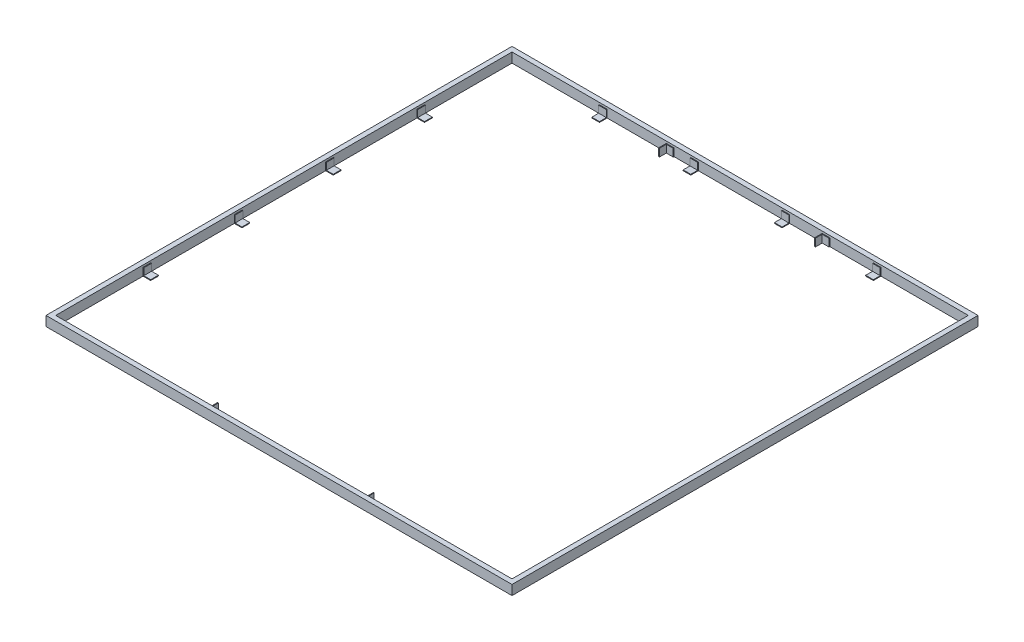
from build123d import *

# Parameters (mm, degrees)
SKETCH1_W                = 3660
SKETCH1_H                = 3660
SKETCH1_W_2              = 3584
SKETCH1_H_2              = 3584
BOSS_EXTRUDE1_DEPTH      = 76
SKETCH2_W                = 60
SKETCH2_H                = 60
BOSS_EXTRUDE2_DEPTH      = 6
SKETCH4_W                = 60
SKETCH4_H                = 6
BOSS_EXTRUDE3_DEPTH      = 54
LPATTERN1_COUNT          = 4
LPATTERN1_PITCH          = 717
MIRROR1_COPY_1_SKETCH_W  = 60
MIRROR1_COPY_1_SKETCH_H  = 60
MIRROR1_COPY_1_DEPTH     = 6
MIRROR1_COPY_2_SKETCH_W  = 60
MIRROR1_COPY_2_SKETCH_H  = 60
MIRROR1_COPY_2_DEPTH     = 6
MIRROR1_COPY_3_SKETCH_W  = 60
MIRROR1_COPY_3_SKETCH_H  = 60
MIRROR1_COPY_3_DEPTH     = 6
MIRROR1_COPY_4_SKETCH_W  = 60
MIRROR1_COPY_4_SKETCH_H  = 6
MIRROR1_COPY_4_DEPTH     = 54
MIRROR1_COPY_5_SKETCH_W  = 60
MIRROR1_COPY_5_SKETCH_H  = 6
MIRROR1_COPY_5_DEPTH     = 54
MIRROR1_COPY_6_SKETCH_W  = 60
MIRROR1_COPY_6_SKETCH_H  = 6
MIRROR1_COPY_6_DEPTH     = 54
MIRROR2_COPY_1_SKETCH_W  = 60
MIRROR2_COPY_1_SKETCH_H  = 60
MIRROR2_COPY_1_DEPTH     = 6
MIRROR2_COPY_2_SKETCH_W  = 60
MIRROR2_COPY_2_SKETCH_H  = 60
MIRROR2_COPY_2_DEPTH     = 6
MIRROR2_COPY_3_SKETCH_W  = 60
MIRROR2_COPY_3_SKETCH_H  = 60
MIRROR2_COPY_3_DEPTH     = 6
MIRROR2_COPY_4_SKETCH_W  = 60
MIRROR2_COPY_4_SKETCH_H  = 6
MIRROR2_COPY_4_DEPTH     = 54
MIRROR2_COPY_5_SKETCH_W  = 60
MIRROR2_COPY_5_SKETCH_H  = 6
MIRROR2_COPY_5_DEPTH     = 54
MIRROR2_COPY_6_SKETCH_W  = 60
MIRROR2_COPY_6_SKETCH_H  = 6
MIRROR2_COPY_6_DEPTH     = 54
MIRROR3_COPY_1_SKETCH_W  = 60
MIRROR3_COPY_1_SKETCH_H  = 60
MIRROR3_COPY_1_DEPTH     = 6
MIRROR3_COPY_2_SKETCH_W  = 60
MIRROR3_COPY_2_SKETCH_H  = 6
MIRROR3_COPY_2_DEPTH     = 54
MIRROR3_COPY_3_SKETCH_W  = 60
MIRROR3_COPY_3_SKETCH_H  = 60
MIRROR3_COPY_3_DEPTH     = 6
MIRROR3_COPY_4_SKETCH_W  = 60
MIRROR3_COPY_4_SKETCH_H  = 60
MIRROR3_COPY_4_DEPTH     = 6
MIRROR3_COPY_5_SKETCH_W  = 60
MIRROR3_COPY_5_SKETCH_H  = 60
MIRROR3_COPY_5_DEPTH     = 6
MIRROR3_COPY_6_SKETCH_W  = 60
MIRROR3_COPY_6_SKETCH_H  = 6
MIRROR3_COPY_6_DEPTH     = 54
MIRROR3_COPY_7_SKETCH_W  = 60
MIRROR3_COPY_7_SKETCH_H  = 6
MIRROR3_COPY_7_DEPTH     = 54
MIRROR3_COPY_8_SKETCH_W  = 60
MIRROR3_COPY_8_SKETCH_H  = 6
MIRROR3_COPY_8_DEPTH     = 54
MIRROR3_COPY_9_SKETCH_W  = 60
MIRROR3_COPY_9_SKETCH_H  = 6
MIRROR3_COPY_9_DEPTH     = 54
MIRROR3_COPY_10_SKETCH_W = 60
MIRROR3_COPY_10_SKETCH_H = 60
MIRROR3_COPY_10_DEPTH    = 6
MIRROR3_COPY_11_SKETCH_W = 60
MIRROR3_COPY_11_SKETCH_H = 60
MIRROR3_COPY_11_DEPTH    = 6
MIRROR3_COPY_12_SKETCH_W = 60
MIRROR3_COPY_12_SKETCH_H = 60
MIRROR3_COPY_12_DEPTH    = 6
MIRROR3_COPY_13_SKETCH_W = 60
MIRROR3_COPY_13_SKETCH_H = 6
MIRROR3_COPY_13_DEPTH    = 54
MIRROR3_COPY_14_SKETCH_W = 60
MIRROR3_COPY_14_SKETCH_H = 6
MIRROR3_COPY_14_DEPTH    = 54
MIRROR3_COPY_15_SKETCH_W = 60
MIRROR3_COPY_15_SKETCH_H = 6
MIRROR3_COPY_15_DEPTH    = 54
MIRROR3_COPY_16_SKETCH_W = 60
MIRROR3_COPY_16_SKETCH_H = 6
MIRROR3_COPY_16_DEPTH    = 54
SKETCH5_W                = 60
SKETCH5_H                = 60
BOSS_EXTRUDE4_DEPTH      = 60
SKETCH7_W                = 54
SKETCH7_H                = 54
CUT_EXTRUDE2_DEPTH       = 60
LPATTERN2_COUNT          = 2
LPATTERN2_PITCH          = 1224
MIRROR4_COPY_1_SKETCH_W  = 60
MIRROR4_COPY_1_SKETCH_H  = 60
MIRROR4_COPY_1_DEPTH     = 60
MIRROR4_COPY_2_SKETCH_W  = 54
MIRROR4_COPY_2_SKETCH_H  = 54
MIRROR4_COPY_2_DEPTH     = 60


with BuildPart() as part:
    # Sketch1 → Boss-Extrude1 (new body)
    with BuildSketch(Plane(origin=(0, 0, 0), x_dir=(1, 0, 0), z_dir=(0, 1, 0))):
        Rectangle(SKETCH1_W, SKETCH1_H)
        Rectangle(SKETCH1_W_2, SKETCH1_H_2, mode=Mode.SUBTRACT)
    extrude(amount=BOSS_EXTRUDE1_DEPTH)

    # Sketch2 → Boss-Extrude2 (add)
    with BuildSketch(Plane(origin=(-1792, 0, 0), x_dir=(0, 0, -1), z_dir=(1, 0, 0))):
        with Locations((-1075, 30)):
            Rectangle(SKETCH2_W, SKETCH2_H)
    boss_extrude2 = extrude(amount=BOSS_EXTRUDE2_DEPTH)

    # Sketch4 → Boss-Extrude3 (add)
    with BuildSketch(Plane(origin=(-1786, 0, 0), x_dir=(0, 0, -1), z_dir=(1, 0, 0))):
        with Locations((-1075, 3)):
            Rectangle(SKETCH4_W, SKETCH4_H)
    boss_extrude3 = extrude(amount=BOSS_EXTRUDE3_DEPTH)

    # LPattern1: Boss-Extrude2, Boss-Extrude3 ×4
    with Locations(*[(0, 0, -i * LPATTERN1_PITCH) for i in range(1, LPATTERN1_COUNT)]):
        add(boss_extrude2)
        add(boss_extrude3)

    # Mirror1: Boss-Extrude2, Boss-Extrude3 across plane
    add(boss_extrude2.mirror(Plane(origin=(0, 0, 0), x_dir=(0, 0, 1), z_dir=(1, 0, 0))))
    add(boss_extrude3.mirror(Plane(origin=(0, 0, 0), x_dir=(0, 0, 1), z_dir=(1, 0, 0))))

    # Mirror1 copy 1 sketch → Mirror1 copy 1 (add)
    with BuildSketch(Plane(origin=(1792, 0, -717), x_dir=(0, 0, -1), z_dir=(-1, 0, 0))):
        with Locations((-1075, -30)):
            Rectangle(MIRROR1_COPY_1_SKETCH_W, MIRROR1_COPY_1_SKETCH_H)
    extrude(amount=MIRROR1_COPY_1_DEPTH)

    # Mirror1 copy 2 sketch → Mirror1 copy 2 (add)
    with BuildSketch(Plane(origin=(1792, 0, -1434), x_dir=(0, 0, -1), z_dir=(-1, 0, 0))):
        with Locations((-1075, -30)):
            Rectangle(MIRROR1_COPY_2_SKETCH_W, MIRROR1_COPY_2_SKETCH_H)
    extrude(amount=MIRROR1_COPY_2_DEPTH)

    # Mirror1 copy 3 sketch → Mirror1 copy 3 (add)
    with BuildSketch(Plane(origin=(1792, 0, -2151), x_dir=(0, 0, -1), z_dir=(-1, 0, 0))):
        with Locations((-1075, -30)):
            Rectangle(MIRROR1_COPY_3_SKETCH_W, MIRROR1_COPY_3_SKETCH_H)
    extrude(amount=MIRROR1_COPY_3_DEPTH)

    # Mirror1 copy 4 sketch → Mirror1 copy 4 (add)
    with BuildSketch(Plane(origin=(1786, 0, -717), x_dir=(0, 0, -1), z_dir=(-1, 0, 0))):
        with Locations((-1075, -3)):
            Rectangle(MIRROR1_COPY_4_SKETCH_W, MIRROR1_COPY_4_SKETCH_H)
    extrude(amount=MIRROR1_COPY_4_DEPTH)

    # Mirror1 copy 5 sketch → Mirror1 copy 5 (add)
    with BuildSketch(Plane(origin=(1786, 0, -1434), x_dir=(0, 0, -1), z_dir=(-1, 0, 0))):
        with Locations((-1075, -3)):
            Rectangle(MIRROR1_COPY_5_SKETCH_W, MIRROR1_COPY_5_SKETCH_H)
    extrude(amount=MIRROR1_COPY_5_DEPTH)

    # Mirror1 copy 6 sketch → Mirror1 copy 6 (add)
    with BuildSketch(Plane(origin=(1786, 0, -2151), x_dir=(0, 0, -1), z_dir=(-1, 0, 0))):
        with Locations((-1075, -3)):
            Rectangle(MIRROR1_COPY_6_SKETCH_W, MIRROR1_COPY_6_SKETCH_H)
    extrude(amount=MIRROR1_COPY_6_DEPTH)

    # Mirror2: Boss-Extrude2, Boss-Extrude3 across plane
    add(boss_extrude2.mirror(Plane(origin=(0, 0, 0), x_dir=(-0.707106781, 0, 0.707106781), z_dir=(-0.707106781, 0, -0.707106781))))
    add(boss_extrude3.mirror(Plane(origin=(0, 0, 0), x_dir=(-0.707106781, 0, 0.707106781), z_dir=(-0.707106781, 0, -0.707106781))))

    # Mirror2 copy 1 sketch → Mirror2 copy 1 (add)
    with BuildSketch(Plane(origin=(717, 0, 1792), x_dir=(1, 0, 0), z_dir=(0, 0, -1))):
        with Locations((-1075, -30)):
            Rectangle(MIRROR2_COPY_1_SKETCH_W, MIRROR2_COPY_1_SKETCH_H)
    extrude(amount=MIRROR2_COPY_1_DEPTH)

    # Mirror2 copy 2 sketch → Mirror2 copy 2 (add)
    with BuildSketch(Plane(origin=(1434, 0, 1792), x_dir=(1, 0, 0), z_dir=(0, 0, -1))):
        with Locations((-1075, -30)):
            Rectangle(MIRROR2_COPY_2_SKETCH_W, MIRROR2_COPY_2_SKETCH_H)
    extrude(amount=MIRROR2_COPY_2_DEPTH)

    # Mirror2 copy 3 sketch → Mirror2 copy 3 (add)
    with BuildSketch(Plane(origin=(2151, 0, 1792), x_dir=(1, 0, 0), z_dir=(0, 0, -1))):
        with Locations((-1075, -30)):
            Rectangle(MIRROR2_COPY_3_SKETCH_W, MIRROR2_COPY_3_SKETCH_H)
    extrude(amount=MIRROR2_COPY_3_DEPTH)

    # Mirror2 copy 4 sketch → Mirror2 copy 4 (add)
    with BuildSketch(Plane(origin=(717, 0, 1786), x_dir=(1, 0, 0), z_dir=(0, 0, -1))):
        with Locations((-1075, -3)):
            Rectangle(MIRROR2_COPY_4_SKETCH_W, MIRROR2_COPY_4_SKETCH_H)
    extrude(amount=MIRROR2_COPY_4_DEPTH)

    # Mirror2 copy 5 sketch → Mirror2 copy 5 (add)
    with BuildSketch(Plane(origin=(1434, 0, 1786), x_dir=(1, 0, 0), z_dir=(0, 0, -1))):
        with Locations((-1075, -3)):
            Rectangle(MIRROR2_COPY_5_SKETCH_W, MIRROR2_COPY_5_SKETCH_H)
    extrude(amount=MIRROR2_COPY_5_DEPTH)

    # Mirror2 copy 6 sketch → Mirror2 copy 6 (add)
    with BuildSketch(Plane(origin=(2151, 0, 1786), x_dir=(1, 0, 0), z_dir=(0, 0, -1))):
        with Locations((-1075, -3)):
            Rectangle(MIRROR2_COPY_6_SKETCH_W, MIRROR2_COPY_6_SKETCH_H)
    extrude(amount=MIRROR2_COPY_6_DEPTH)

    # Mirror3: Boss-Extrude2 across plane
    add(boss_extrude2.mirror(Plane.XY))

    # Mirror3 copy 1 sketch → Mirror3 copy 1 (add)
    with BuildSketch(Plane.XY.offset(-1792)):
        with Locations((-1075, 30)):
            Rectangle(MIRROR3_COPY_1_SKETCH_W, MIRROR3_COPY_1_SKETCH_H)
    extrude(amount=MIRROR3_COPY_1_DEPTH)

    # Mirror3 copy 2 sketch → Mirror3 copy 2 (add)
    with BuildSketch(Plane.XY.offset(-1786)):
        with Locations((-1075, 3)):
            Rectangle(MIRROR3_COPY_2_SKETCH_W, MIRROR3_COPY_2_SKETCH_H)
    extrude(amount=MIRROR3_COPY_2_DEPTH)

    # Mirror3 copy 3 sketch → Mirror3 copy 3 (add)
    with BuildSketch(Plane(origin=(717, 0, -1792), x_dir=(1, 0, 0), z_dir=(0, 0, 1))):
        with Locations((-1075, 30)):
            Rectangle(MIRROR3_COPY_3_SKETCH_W, MIRROR3_COPY_3_SKETCH_H)
    extrude(amount=MIRROR3_COPY_3_DEPTH)

    # Mirror3 copy 4 sketch → Mirror3 copy 4 (add)
    with BuildSketch(Plane(origin=(1434, 0, -1792), x_dir=(1, 0, 0), z_dir=(0, 0, 1))):
        with Locations((-1075, 30)):
            Rectangle(MIRROR3_COPY_4_SKETCH_W, MIRROR3_COPY_4_SKETCH_H)
    extrude(amount=MIRROR3_COPY_4_DEPTH)

    # Mirror3 copy 5 sketch → Mirror3 copy 5 (add)
    with BuildSketch(Plane(origin=(2151, 0, -1792), x_dir=(1, 0, 0), z_dir=(0, 0, 1))):
        with Locations((-1075, 30)):
            Rectangle(MIRROR3_COPY_5_SKETCH_W, MIRROR3_COPY_5_SKETCH_H)
    extrude(amount=MIRROR3_COPY_5_DEPTH)

    # Mirror3 copy 6 sketch → Mirror3 copy 6 (add)
    with BuildSketch(Plane(origin=(717, 0, -1786), x_dir=(1, 0, 0), z_dir=(0, 0, 1))):
        with Locations((-1075, 3)):
            Rectangle(MIRROR3_COPY_6_SKETCH_W, MIRROR3_COPY_6_SKETCH_H)
    extrude(amount=MIRROR3_COPY_6_DEPTH)

    # Mirror3 copy 7 sketch → Mirror3 copy 7 (add)
    with BuildSketch(Plane(origin=(1434, 0, -1786), x_dir=(1, 0, 0), z_dir=(0, 0, 1))):
        with Locations((-1075, 3)):
            Rectangle(MIRROR3_COPY_7_SKETCH_W, MIRROR3_COPY_7_SKETCH_H)
    extrude(amount=MIRROR3_COPY_7_DEPTH)

    # Mirror3 copy 8 sketch → Mirror3 copy 8 (add)
    with BuildSketch(Plane(origin=(2151, 0, -1786), x_dir=(1, 0, 0), z_dir=(0, 0, 1))):
        with Locations((-1075, 3)):
            Rectangle(MIRROR3_COPY_8_SKETCH_W, MIRROR3_COPY_8_SKETCH_H)
    extrude(amount=MIRROR3_COPY_8_DEPTH)

    # Mirror3 copy 9 sketch → Mirror3 copy 9 (add)
    with BuildSketch(Plane(origin=(-1786, 0, 0), x_dir=(0, 0, 1), z_dir=(1, 0, 0))):
        with Locations((-1075, -3)):
            Rectangle(MIRROR3_COPY_9_SKETCH_W, MIRROR3_COPY_9_SKETCH_H)
    extrude(amount=MIRROR3_COPY_9_DEPTH)

    # Mirror3 copy 10 sketch → Mirror3 copy 10 (add)
    with BuildSketch(Plane(origin=(-1792, 0, 717), x_dir=(0, 0, 1), z_dir=(1, 0, 0))):
        with Locations((-1075, -30)):
            Rectangle(MIRROR3_COPY_10_SKETCH_W, MIRROR3_COPY_10_SKETCH_H)
    extrude(amount=MIRROR3_COPY_10_DEPTH)

    # Mirror3 copy 11 sketch → Mirror3 copy 11 (add)
    with BuildSketch(Plane(origin=(-1792, 0, 1434), x_dir=(0, 0, 1), z_dir=(1, 0, 0))):
        with Locations((-1075, -30)):
            Rectangle(MIRROR3_COPY_11_SKETCH_W, MIRROR3_COPY_11_SKETCH_H)
    extrude(amount=MIRROR3_COPY_11_DEPTH)

    # Mirror3 copy 12 sketch → Mirror3 copy 12 (add)
    with BuildSketch(Plane(origin=(-1792, 0, 2151), x_dir=(0, 0, 1), z_dir=(1, 0, 0))):
        with Locations((-1075, -30)):
            Rectangle(MIRROR3_COPY_12_SKETCH_W, MIRROR3_COPY_12_SKETCH_H)
    extrude(amount=MIRROR3_COPY_12_DEPTH)

    # Mirror3 copy 13 sketch → Mirror3 copy 13 (add)
    with BuildSketch(Plane(origin=(-1786, 0, 717), x_dir=(0, 0, 1), z_dir=(1, 0, 0))):
        with Locations((-1075, -3)):
            Rectangle(MIRROR3_COPY_13_SKETCH_W, MIRROR3_COPY_13_SKETCH_H)
    extrude(amount=MIRROR3_COPY_13_DEPTH)

    # Mirror3 copy 14 sketch → Mirror3 copy 14 (add)
    with BuildSketch(Plane(origin=(-1786, 0, 1434), x_dir=(0, 0, 1), z_dir=(1, 0, 0))):
        with Locations((-1075, -3)):
            Rectangle(MIRROR3_COPY_14_SKETCH_W, MIRROR3_COPY_14_SKETCH_H)
    extrude(amount=MIRROR3_COPY_14_DEPTH)

    # Mirror3 copy 15 sketch → Mirror3 copy 15 (add)
    with BuildSketch(Plane(origin=(-1786, 0, 2151), x_dir=(0, 0, 1), z_dir=(1, 0, 0))):
        with Locations((-1075, -3)):
            Rectangle(MIRROR3_COPY_15_SKETCH_W, MIRROR3_COPY_15_SKETCH_H)
    extrude(amount=MIRROR3_COPY_15_DEPTH)

    # Mirror3 copy 16 sketch → Mirror3 copy 16 (add)
    with BuildSketch(Plane(origin=(-1786, 0, 0), x_dir=(0, 0, 1), z_dir=(1, 0, 0))):
        with Locations((-1075, -3)):
            Rectangle(MIRROR3_COPY_16_SKETCH_W, MIRROR3_COPY_16_SKETCH_H)
    extrude(amount=MIRROR3_COPY_16_DEPTH)

    # Sketch5 → Boss-Extrude4 (add)
    with BuildSketch(Plane(origin=(0, 0, 1792), x_dir=(-1, 0, 0), z_dir=(0, 0, -1))):
        with Locations((550, 30)):
            Rectangle(SKETCH5_W, SKETCH5_H)
    boss_extrude4 = extrude(amount=BOSS_EXTRUDE4_DEPTH)

    # Sketch7 → Cut-Extrude2 (cut)
    with BuildSketch(Plane(origin=(0, 60, 0), x_dir=(1, 0, 0), z_dir=(0, 1, 0))):
        with Locations((-547, -1759)):
            Rectangle(SKETCH7_W, SKETCH7_H)
    cut_extrude2 = extrude(amount=-CUT_EXTRUDE2_DEPTH, mode=Mode.SUBTRACT)

    # LPattern2: Boss-Extrude4, Cut-Extrude2 ×2
    with Locations(*[(i * LPATTERN2_PITCH, 0, 0) for i in range(1, LPATTERN2_COUNT)]):
        add(boss_extrude4)
        add(cut_extrude2, mode=Mode.SUBTRACT)

    # Mirror4: Boss-Extrude4, Cut-Extrude2 across plane
    add(boss_extrude4.mirror(Plane.XY))
    add(cut_extrude2.mirror(Plane.XY), mode=Mode.SUBTRACT)

    # Mirror4 copy 1 sketch → Mirror4 copy 1 (add)
    with BuildSketch(Plane(origin=(1224, 0, -1792), x_dir=(-1, 0, 0), z_dir=(0, 0, 1))):
        with Locations((550, -30)):
            Rectangle(MIRROR4_COPY_1_SKETCH_W, MIRROR4_COPY_1_SKETCH_H)
    extrude(amount=MIRROR4_COPY_1_DEPTH)

    # Mirror4 copy 2 sketch → Mirror4 copy 2 (cut)
    with BuildSketch(Plane(origin=(1224, 60, 0), x_dir=(1, 0, 0), z_dir=(0, 1, 0))):
        with Locations((-547, 1759)):
            Rectangle(MIRROR4_COPY_2_SKETCH_W, MIRROR4_COPY_2_SKETCH_H)
    extrude(amount=-MIRROR4_COPY_2_DEPTH, mode=Mode.SUBTRACT)


solid = part.part
